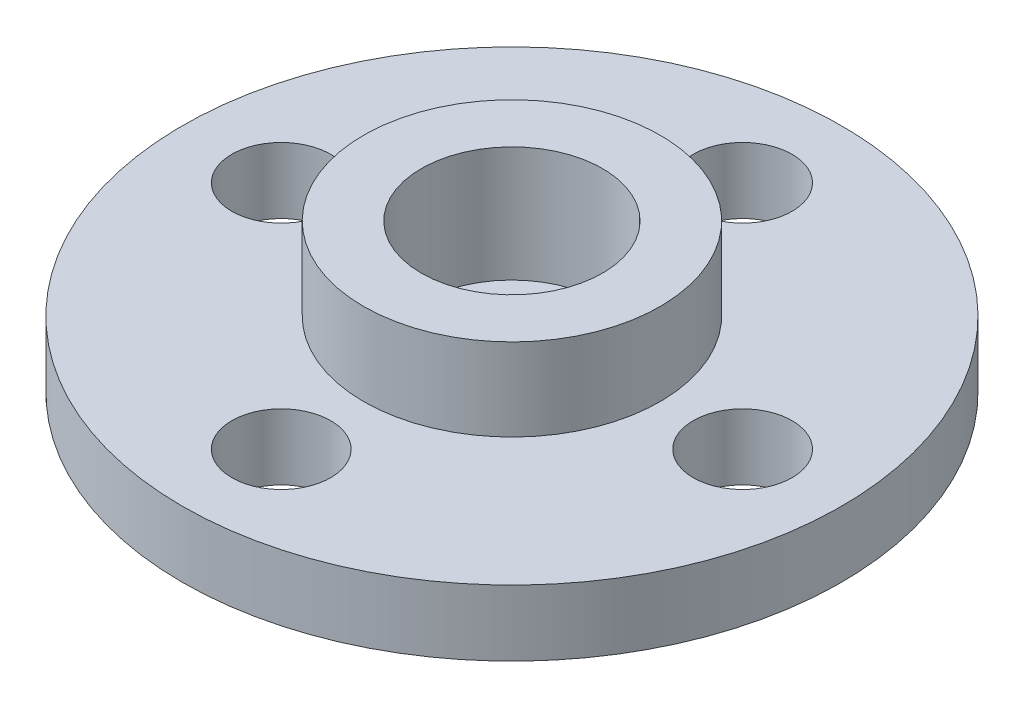
from build123d import *

# Parameters (mm, degrees)
SKETCH1_R           = 10
BOSS_EXTRUDE1_DEPTH = 2
SKETCH2_R           = 4.5
BOSS_EXTRUDE2_DEPTH = 2.5
SKETCH3_R           = 2.75
CUT_EXTRUDE1_DEPTH  = 3.5
SKETCH4_R           = 1.5
CUT_EXTRUDE2_DEPTH  = 2
SKETCH5_R           = 1.5
CUT_EXTRUDE3_DEPTH  = 3


with BuildPart() as part:
    # Sketch1 → Boss-Extrude1 (new body)
    with BuildSketch(Plane(origin=(0, 0, 0), x_dir=(1, 0, 0), z_dir=(0, 1, 0))):
        Circle(SKETCH1_R)
    extrude(amount=BOSS_EXTRUDE1_DEPTH)

    # Sketch2 → Boss-Extrude2 (add)
    with BuildSketch(Plane(origin=(0, 2, 0), x_dir=(1, 0, 0), z_dir=(0, 1, 0))):
        Circle(SKETCH2_R)
    extrude(amount=BOSS_EXTRUDE2_DEPTH)

    # Sketch3 → Cut-Extrude1 (cut)
    with BuildSketch(Plane(origin=(0, 4.5, 0), x_dir=(1, 0, 0), z_dir=(0, 1, 0))):
        Circle(SKETCH3_R)
    extrude(amount=-CUT_EXTRUDE1_DEPTH, mode=Mode.SUBTRACT)

    # Sketch4 → Cut-Extrude2 (cut, through all)
    with BuildSketch(Plane(origin=(0, 1, 0), x_dir=(1, 0, 0), z_dir=(0, 1, 0))):
        Circle(SKETCH4_R)
    extrude(amount=-CUT_EXTRUDE2_DEPTH, mode=Mode.SUBTRACT)

    # Sketch5 → Cut-Extrude3 (cut, through all)
    with BuildSketch(Plane(origin=(0, 2, 0), x_dir=(1, 0, 0), z_dir=(0, 1, 0))):
        with Locations((0, 7)):
            Circle(SKETCH5_R)
        with Locations((7, 0)):
            Circle(SKETCH5_R)
        with Locations((0, -7)):
            Circle(SKETCH5_R)
        with Locations((-7, 0)):
            Circle(SKETCH5_R)
    extrude(amount=-CUT_EXTRUDE3_DEPTH, mode=Mode.SUBTRACT)


solid = part.part
